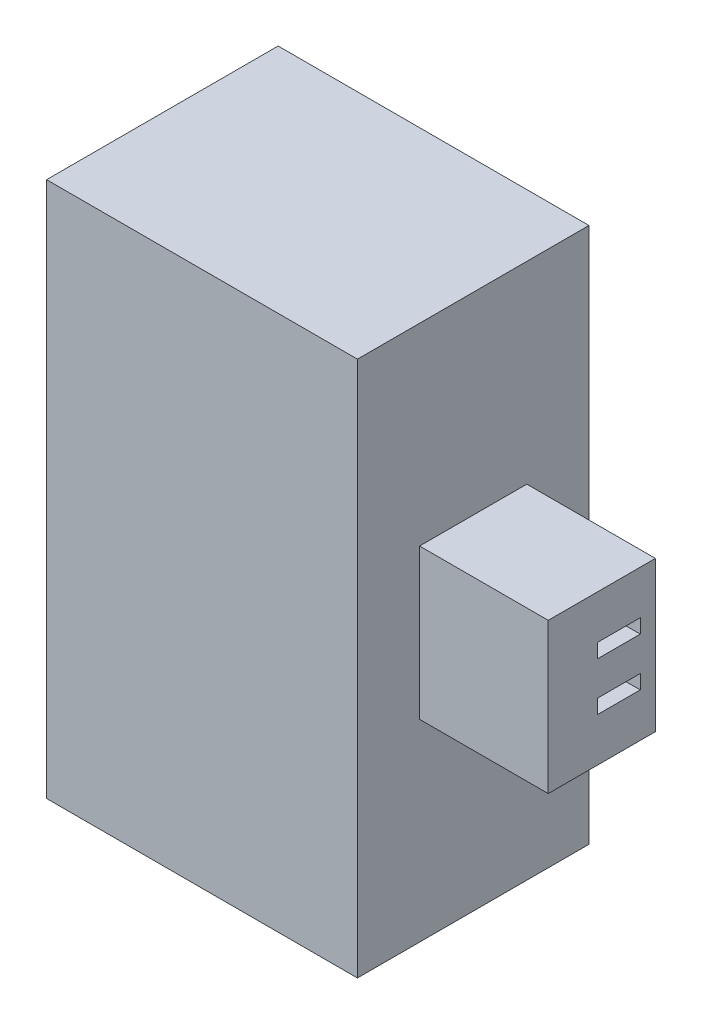
from build123d import *

# Parameters (mm, degrees)
SKETCH1_W           = 7.25
SKETCH1_H           = 12.5
BOSS_EXTRUDE1_DEPTH = 5.4
SKETCH3_W           = 2.5
SKETCH3_H           = 3.5
SKETCH3_W_2         = 1
SKETCH3_H_2         = 0.331350256
BOSS_EXTRUDE2_DEPTH = 3


with BuildPart() as part:
    # Sketch1 → Boss-Extrude1 (new body)
    with BuildSketch(Plane.XY):
        with Locations((3.625, 6.25)):
            Rectangle(SKETCH1_W, SKETCH1_H)
    extrude(amount=BOSS_EXTRUDE1_DEPTH)

    # Sketch3 → Boss-Extrude2 (add)
    with BuildSketch(Plane(origin=(7.25, 0, 0), x_dir=(0, 0, -1), z_dir=(1, 0, 0))):
        with Locations((-2.7, 6.25)):
            Rectangle(SKETCH3_W, SKETCH3_H)
        with Locations((-2.303664878, 5.686580017)):
            Rectangle(SKETCH3_W_2, SKETCH3_H_2, mode=Mode.SUBTRACT)
        with Locations((-2.303664878, 6.813419983)):
            Rectangle(SKETCH3_W_2, SKETCH3_H_2, mode=Mode.SUBTRACT)
    extrude(amount=BOSS_EXTRUDE2_DEPTH)


solid = part.part
